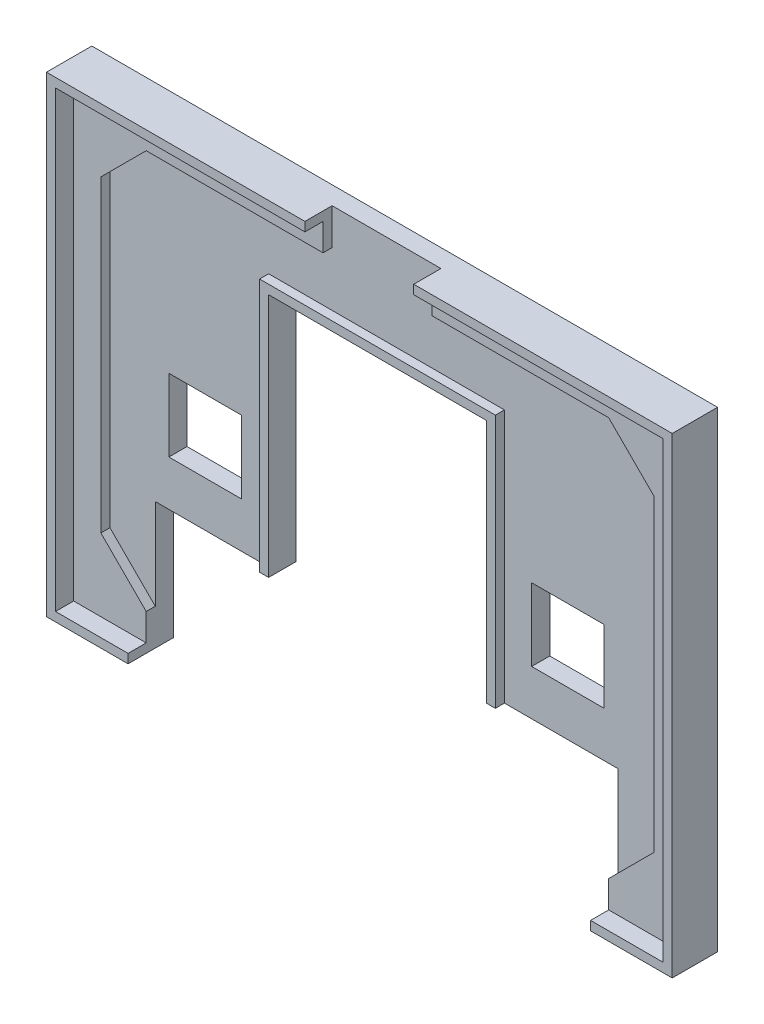
from build123d import *

# Parameters (mm, degrees)
SKICA1_W                    = 67
SKICA1_H                    = 50
P_IDAT_VYSUNUT_M1_DEPTH     = 3
ODEBRAT_VYSUNUT_M1_DEPTH    = 1
SKICA3_W                    = 8
SKICA3_H                    = 8
ODEBRAT_VYSUNUT_M2_DEPTH    = 4
VYSUNOUT_TENKOST_NN_1_DEPTH = 1
VYSUNOUT_TENKOST_NN_2_DEPTH = 5
SKICA6_W                    = 12
SKICA6_H                    = 4
ODEBRAT_VYSUNUT_M3_DEPTH    = 4
ODEBRAT_VYSUNUT_M4_DEPTH    = 1
ODEBRAT_VYSUNUT_M5_DEPTH    = 1


with BuildPart() as part:
    # Skica1 → Přidat vysunutím1 (new body)
    with BuildSketch(Plane.XY):
        Rectangle(SKICA1_W, SKICA1_H)
    extrude(amount=P_IDAT_VYSUNUT_M1_DEPTH)

    # Skica2 → Odebrat vysunutím1 (cut)
    with BuildSketch(Plane.XY.offset(3)):
        Polygon((-25.5, -22), (-30.5, -17), (-30.5, 17), (-25.5, 22), (25.5, 22), (30.5, 17), (30.5, -17), (25.5, -22), align=None)
    extrude(amount=-ODEBRAT_VYSUNUT_M1_DEPTH, mode=Mode.SUBTRACT)

    # Skica3 → Odebrat vysunutím2 (cut, through all)
    with BuildSketch(Plane(origin=(0, 0, 0), x_dir=(-1, 0, 0), z_dir=(0, 0, -1))):
        with Locations((20, -3)):
            Rectangle(SKICA3_W, SKICA3_H)
        with Locations((-20, -3)):
            Rectangle(SKICA3_W, SKICA3_H)
        Polygon((25.5, -25), (-25.5, -25), (-25.5, -12), (-12, -12), (-12, 15), (12, 15), (12, -12), (25.5, -12), align=None)
    extrude(amount=-ODEBRAT_VYSUNUT_M2_DEPTH, mode=Mode.SUBTRACT)

    # Skica4 → Vysunout tenkostěnný1 (add)
    with BuildSketch(Plane.XY.offset(2)):
        Polygon((-12, -12), (-12, 15), (12, 15), (12, -12), (13, -12), (13, 16), (-13, 16), (-13, -12), align=None)
    extrude(amount=VYSUNOUT_TENKOST_NN_1_DEPTH)

    # Skica5 → Vysunout tenkostěnný2 (add)
    with BuildSketch(Plane(origin=(0, 0, 0), x_dir=(-1, 0, 0), z_dir=(0, 0, -1))):
        Polygon((-25.5, -25), (-33.5, -25), (-33.5, 25), (33.5, 25), (33.5, -25), (25.5, -25), (25.5, -26), (34.5, -26), (34.5, 26), (-34.5, 26), (-34.5, -26), (-25.5, -26), align=None)
    extrude(amount=-VYSUNOUT_TENKOST_NN_2_DEPTH)

    # Skica6 → Odebrat vysunutím3 (cut, through all)
    with BuildSketch(Plane.XY.offset(2)):
        with Locations((0, 24)):
            Rectangle(SKICA6_W, SKICA6_H)
    extrude(amount=ODEBRAT_VYSUNUT_M3_DEPTH, mode=Mode.SUBTRACT)

    # Skica7 → Odebrat vysunutím4 (cut)
    with BuildSketch(Plane(origin=(0, 0, 0), x_dir=(-1, 0, 0), z_dir=(0, 0, -1))):
        Polygon((-29.257189592, 22.893008351), (-26.612015185, 22.893008351), (-26.612015185, 21.848860559), (-25.335834551, 21.848860559), (-25.335834551, 17.045780717), (-26.612015185, 17.045780717), (-26.612015185, 15.955226356), (-29.257189592, 15.955226356), (-29.257189592, 17.045780717), (-30.602980079, 17.045780717), (-30.602980079, 20.595883209), (-29.257189592, 20.595883209), align=None)
        Polygon((-19.952672602, 22.893008351), (-21.252056521, 22.893008351), (-21.252056521, 21.848860559), (-22.551440439, 21.848860559), (-22.551440439, 17.045780717), (-21.252056521, 17.045780717), (-21.252056521, 15.955226356), (-15.938504424, 15.955226356), (-15.938504424, 18.04352194), (-17.191481774, 18.04352194), (-17.191481774, 20.595883209), (-18.595280472, 20.595883209), (-18.595280472, 21.848860559), (-19.952672602, 21.848860559), align=None)
        Polygon((-30.602980079, 14.493419448), (-29.257189592, 14.493419448), (-29.257189592, 13.402865087), (-27.934602389, 13.402865087), (-27.934602389, 14.493419448), (-26.612015185, 14.493419448), (-26.612015185, 13.402865087), (-23.920434211, 13.402865087), (-23.920434211, 14.493419448), (-22.551440439, 14.493419448), (-22.551440439, 13.402865087), (-19.952672602, 13.402865087), (-19.952672602, 14.493419448), (-18.595280472, 14.493419448), (-18.595280472, 13.402865087), (-17.191481774, 13.402865087), (-17.191481774, 14.493419448), (-15.938504424, 14.493419448), (-15.938504424, 12.242700874), (-14.592713937, 12.242700874), (-14.592713937, 9.643933037), (-17.191481774, 9.643933037), (-17.191481774, 10.943316955), (-18.595280472, 10.943316955), (-18.595280472, 8.622988529), (-19.952672602, 8.622988529), (-19.952672602, 9.783152742), (-22.551440439, 9.783152742), (-22.551440439, 10.943316955), (-23.920434211, 10.943316955), (-23.920434211, 9.783152742), (-25.266224698, 9.783152742), (-25.266224698, 9.643933037), (-25.266224698, 8.622988529), (-26.612015185, 8.622988529), (-26.612015185, 10.943316955), (-27.934602389, 10.943316955), (-27.934602389, 9.643933037), (-29.257189592, 9.643933037), (-29.396409297, 9.643933037), (-29.396409297, 8.622988529), (-30.602980079, 8.622988529), (-30.602980079, 10.943316955), (-31.97197385, 10.943316955), (-31.97197385, 13.402865087), (-30.602980079, 13.402865087), align=None)
        Polygon((23.920434211, 9.783152742), (25.266224698, 9.783152742), (25.266224698, 9.643933037), (25.266224698, 8.622988529), (26.612015185, 8.622988529), (26.612015185, 10.943316955), (27.934602389, 10.943316955), (27.934602389, 9.643933037), (29.257189592, 9.643933037), (29.396409297, 9.643933037), (29.396409297, 8.622988529), (30.602980079, 8.622988529), (30.602980079, 10.943316955), (31.97197385, 10.943316955), (31.97197385, 13.402865087), (30.602980079, 13.402865087), (30.602980079, 14.493419448), (29.257189592, 14.493419448), (29.257189592, 13.402865087), (27.934602389, 13.402865087), (27.934602389, 14.493419448), (26.612015185, 14.493419448), (26.612015185, 13.402865087), (23.920434211, 13.402865087), (23.920434211, 14.493419448), (22.551440439, 14.493419448), (22.551440439, 13.402865087), (19.952672602, 13.402865087), (19.952672602, 14.493419448), (18.595280472, 14.493419448), (18.595280472, 13.402865087), (17.191481774, 13.402865087), (17.191481774, 14.493419448), (15.938504424, 14.493419448), (15.938504424, 12.242700874), (14.592713937, 12.242700874), (14.592713937, 9.643933037), (17.191481774, 9.643933037), (17.191481774, 10.943316955), (18.595280472, 10.943316955), (18.595280472, 8.622988529), (19.952672602, 8.622988529), (19.952672602, 9.783152742), (22.551440439, 9.783152742), (22.551440439, 10.943316955), (23.920434211, 10.943316955), align=None)
        Polygon((18.595280472, 21.848860559), (19.952672602, 21.848860559), (19.952672602, 22.893008351), (21.252056521, 22.893008351), (21.252056521, 21.848860559), (22.551440439, 21.848860559), (22.551440439, 17.045780717), (21.252056521, 17.045780717), (21.252056521, 15.955226356), (15.938504424, 15.955226356), (15.938504424, 18.04352194), (17.191481774, 18.04352194), (17.191481774, 20.595883209), (18.595280472, 20.595883209), align=None)
        Polygon((30.602980079, 20.595883209), (29.257189592, 20.595883209), (29.257189592, 22.893008351), (26.612015185, 22.893008351), (26.612015185, 21.848860559), (25.335834551, 21.848860559), (25.335834551, 17.045780717), (26.612015185, 17.045780717), (26.612015185, 15.955226356), (29.257189592, 15.955226356), (29.257189592, 17.045780717), (30.602980079, 17.045780717), align=None)
    extrude(amount=-ODEBRAT_VYSUNUT_M4_DEPTH, mode=Mode.SUBTRACT)

    # Skica8 → Odebrat vysunutím5 (cut)
    with BuildSketch(Plane(origin=(0, 0, 0), x_dir=(-1, 0, 0), z_dir=(0, 0, -1))):
        with BuildLine():
            add(Edge.make_bspline(
                [(-10.847232938, 22.82708346), (-10.846592487, 22.855861446), (-10.845391224, 22.909838983), (-10.841341175, 22.985738224), (-10.838152904, 23.05171888), (-10.833745096, 23.107762749), (-10.827344732, 23.153621635), (-10.822109294, 23.189512345), (-10.81537596, 23.215389421), (-10.803630622, 23.239888734), (-10.767463549, 23.257849053), (-10.709032498, 23.269282424), (-10.623172668, 23.278410789), (-10.530397944, 23.282452405), (-10.426453879, 23.285723657), (-10.308952592, 23.286198512), (-10.15550219, 23.287632538), (-9.966084133, 23.28872804), (-9.740302071, 23.289870296), (-9.478556149, 23.291413513), (-9.180442007, 23.290921624), (-8.969845503, 23.290996085), (-8.858353235, 23.291035506)],
                knots=[0, 0, 0, 0, 8.635e-05, 0.000161963, 0.000227997, 0.000284546, 0.000330495, 0.000366956, 0.000393139, 0.00041084, 0.000446424, 0.000506903, 0.000591368, 0.000704219, 0.000785775, 0.000903268, 0.001056724, 0.001246145, 0.001471531, 0.00173408, 0.002031393, 0.00236587, 0.00236587, 0.00236587, 0.00236587], degree=3))
            add(Edge.make_bspline(
                [(-8.858353235, 23.291035506), (-8.781626727, 23.291210694), (-8.632968006, 23.291550123), (-8.417183219, 23.289178891), (-8.215762162, 23.29081177), (-8.029162571, 23.286888665), (-7.856910535, 23.286760549), (-7.699070598, 23.283895751), (-7.555212749, 23.2814602), (-7.425711502, 23.279605178), (-7.310648325, 23.27548905), (-7.209893282, 23.272540012), (-7.123614489, 23.267398802), (-7.051632855, 23.262856217), (-6.994161048, 23.257955056), (-6.950642876, 23.253936774), (-6.921977591, 23.248374995), (-6.900217213, 23.241342845), (-6.887952998, 23.221635367), (-6.876426571, 23.195551877), (-6.865735488, 23.160439922), (-6.857475567, 23.116304859), (-6.852317493, 23.062918768), (-6.847100635, 23.000607594), (-6.845269934, 22.929392348), (-6.844635255, 22.879032172), (-6.844297841, 22.852259152)],
                knots=[0, 0, 0, 0, 0.000230178, 0.000445973, 0.000647378, 0.000834413, 0.001005852, 0.001164117, 0.001307998, 0.001437495, 0.00155264, 0.001653407, 0.001739857, 0.001811947, 0.001869691, 0.001913115, 0.001942505, 0.00195809, 0.001979435, 0.002008406, 0.002044808, 0.002088775, 0.002143055, 0.002205579, 0.002276351, 0.002356683, 0.002356683, 0.002356683, 0.002356683], degree=3))
            Line((-6.844297841, 22.852259152), (-6.844297841, 22.504594828))
            Line((-6.844297841, 22.504594828), (-6.579353649, 22.504594828))
            Line((-6.579353649, 22.504594828), (-6.463065927, 22.504594828))
            add(Edge.make_bspline(
                [(-6.463065927, 22.504594828), (-6.437010547, 22.503607805), (-6.389324864, 22.501801389), (-6.325227392, 22.485439746), (-6.27785123, 22.453695141), (-6.252452965, 22.415689464), (-6.24275747, 22.376518543), (-6.233680058, 22.336763538), (-6.228830898, 22.285657639), (-6.22425393, 22.224096449), (-6.218735037, 22.15221447), (-6.217521022, 22.06900721), (-6.214133866, 21.975127971), (-6.214640201, 21.908774163), (-6.21490553, 21.874003674)],
                knots=[0, 0, 0, 0, 7.8155e-05, 0.000143037, 0.000195581, 0.000245789, 0.00027576, 0.000316203, 0.0003681, 0.000429429, 0.000501519, 0.000584274, 0.000679013, 0.000783312, 0.000783312, 0.000783312, 0.000783312], degree=3))
            Line((-6.21490553, 21.874003674), (-6.21490553, 21.576690735))
            add(Edge.make_bspline(
                [(-6.21490553, 21.576690735), (-6.215384154, 21.513552917), (-6.21628385, 21.394869479), (-6.216371123, 21.228201084), (-6.220914344, 21.084758182), (-6.223494623, 20.964431418), (-6.229282274, 20.867187227), (-6.236822195, 20.793028127), (-6.242450039, 20.740866454), (-6.252178187, 20.715445619), (-6.255666175, 20.706331083)],
                knots=[0, 0, 0, 0, 0.000189421, 0.000356064, 0.00049997, 0.000619909, 0.0007172, 0.000791875, 0.000844104, 0.000873298, 0.000873298, 0.000873298, 0.000873298], degree=3))
            add(Edge.make_bspline(
                [(-6.255666175, 20.706331083), (-6.267247633, 20.697158974), (-6.296338203, 20.674120264), (-6.364539331, 20.658788881), (-6.45780779, 20.648940319), (-6.530103786, 20.648076172), (-6.570961751, 20.6475878)],
                knots=[0, 0, 0, 0, 4.3901e-05, 0.000110272, 0.000204402, 0.000326737, 0.000326737, 0.000326737, 0.000326737], degree=3))
            Line((-6.570961751, 20.6475878), (-6.844297841, 20.6475878))
            Line((-6.844297841, 20.6475878), (-6.844297841, 20.308315374))
            add(Edge.make_bspline(
                [(-6.844297841, 20.308315374), (-6.844583394, 20.280739391), (-6.845117366, 20.229173494), (-6.847573146, 20.156034169), (-6.850927091, 20.092447552), (-6.855585805, 20.037630215), (-6.861640301, 19.992450376), (-6.872578666, 19.956855503), (-6.880222845, 19.929396629), (-6.895570278, 19.905193331), (-6.937017585, 19.8946851), (-7.002702786, 19.887425563), (-7.105646428, 19.877018013), (-7.243827479, 19.871627784), (-7.418098076, 19.863359519), (-7.628736414, 19.859999034), (-7.874878817, 19.854169345), (-8.051128651, 19.853246797), (-8.14504195, 19.852755225)],
                knots=[0, 0, 0, 0, 8.2729e-05, 0.000154699, 0.000219537, 0.000273697, 0.000319818, 0.000355883, 0.000385076, 0.000405702, 0.000437982, 0.000505799, 0.000608151, 0.000746205, 0.000921384, 0.001131236, 0.001378244, 0.001659982, 0.001659982, 0.001659982, 0.001659982], degree=3))
            Line((-8.14504195, 19.852755225), (-9.363065927, 19.844363327))
            Line((-9.363065927, 19.844363327), (-9.363065927, 18.725843278))
            add(Edge.make_bspline(
                [(-9.363065927, 18.725843278), (-9.363753306, 18.638328597), (-9.365043366, 18.474082552), (-9.36850193, 18.244271491), (-9.373324999, 18.047322786), (-9.378562982, 17.883242817), (-9.38673514, 17.753109912), (-9.391323371, 17.654147743), (-9.402476596, 17.591981161), (-9.4079462, 17.548419559), (-9.438132786, 17.531455287), (-9.477383918, 17.521528755), (-9.536338952, 17.512378295), (-9.613430096, 17.504205722), (-9.710298026, 17.498901468), (-9.825767038, 17.493821278), (-9.96088565, 17.491997112), (-10.057196681, 17.491370756), (-10.10874596, 17.491035506)],
                knots=[0, 0, 0, 0, 0.000262557, 0.000492763, 0.000689432, 0.000853783, 0.000984654, 0.001082027, 0.001147471, 0.001180083, 0.00120336, 0.001244698, 0.001303037, 0.001381412, 0.001477506, 0.001593893, 0.001728185, 0.00188284, 0.00188284, 0.00188284, 0.00188284], degree=3))
            add(Edge.make_bspline(
                [(-10.10874596, 17.491035506), (-10.146309452, 17.491074723), (-10.21704071, 17.491148568), (-10.317349531, 17.490661728), (-10.405660691, 17.49220369), (-10.482784755, 17.493360177), (-10.547929066, 17.4944274), (-10.601461765, 17.495886588), (-10.643090205, 17.496367309), (-10.681481203, 17.49972708), (-10.718408989, 17.503798675), (-10.754805391, 17.514735479), (-10.78395607, 17.528671643), (-10.804644431, 17.545091928), (-10.815452949, 17.566574102), (-10.82207515, 17.592606318), (-10.82735812, 17.628430804), (-10.833739753, 17.674315094), (-10.838156868, 17.730349738), (-10.841329947, 17.796333786), (-10.845440237, 17.872230752), (-10.846808684, 17.94379757), (-10.848907269, 18.011722727), (-10.848008451, 18.077276488), (-10.849827691, 18.155990878), (-10.851236706, 18.248299513), (-10.850347853, 18.353807005), (-10.852543767, 18.472882844), (-10.851954188, 18.605160296), (-10.85169105, 18.751021677), (-10.853668117, 18.909662637), (-10.853183926, 19.081899728), (-10.852863782, 19.267322741), (-10.854887486, 19.466325742), (-10.854290448, 19.678523854), (-10.854466003, 19.904305333), (-10.854413631, 20.143274755), (-10.854432324, 20.391035506), (-10.854413631, 20.638796256), (-10.854466003, 20.877765678), (-10.854290448, 21.103547158), (-10.854887486, 21.31574527), (-10.852863782, 21.514748271), (-10.853183927, 21.700171284), (-10.853668114, 21.872408375), (-10.85169106, 22.031049335), (-10.851954154, 22.176910715), (-10.852543876, 22.30918817), (-10.85034751, 22.428263999), (-10.851237775, 22.533771521), (-10.849824444, 22.626080065), (-10.848017926, 22.704794726), (-10.848881028, 22.770347726), (-10.847743664, 22.809501647), (-10.847232938, 22.82708346)],
                knots=[0, 0, 0, 0, 0.000112691, 0.000212195, 0.000300918, 0.000377653, 0.0004436, 0.000496363, 0.000538339, 0.000568406, 0.000611979, 0.000649528, 0.000681696, 0.000708876, 0.000726576, 0.000752759, 0.000789221, 0.000835169, 0.000891719, 0.000957753, 0.001033366, 0.001119716, 0.001172478, 0.001237216, 0.001316349, 0.001408667, 0.001514165, 0.001632857, 0.001765928, 0.001910988, 0.002070439, 0.002241873, 0.002427694, 0.002626705, 0.002838901, 0.003064283, 0.003304051, 0.003555808, 0.003807565, 0.004047334, 0.004272716, 0.004484911, 0.004683923, 0.004869743, 0.005041178, 0.005200628, 0.005345688, 0.00547876, 0.005597451, 0.005702949, 0.005795268, 0.005874401, 0.005939138, 0.005991901, 0.005991901, 0.005991901, 0.005991901], degree=3))
        make_face()
        with BuildLine():
            add(Edge.make_bspline(
                [(-7.706265596, 20.937707684), (-7.706265596, 20.939306141), (-7.706265596, 20.946099582), (-7.706265596, 20.960885306), (-7.706265596, 20.986060998), (-7.706265596, 21.020827431), (-7.706265596, 21.065983832), (-7.706265596, 21.120730972), (-7.706265596, 21.185468467), (-7.706265596, 21.260196316), (-7.706265596, 21.344914519), (-7.706265596, 21.439623076), (-7.706265596, 21.544321988), (-7.706265596, 21.659011253), (-7.706265596, 21.783690873), (-7.706265596, 21.918360847), (-7.706265596, 22.063021175), (-7.706265596, 22.162924716), (-7.706265596, 22.214474944)],
                knots=[0, 0, 0, 0, 4.795e-06, 2.038e-05, 4.4357e-05, 8.0322e-05, 0.00012468, 0.000179826, 0.000244564, 0.000318892, 0.00040401, 0.000498718, 0.000603018, 0.000718107, 0.000842786, 0.000977057, 0.001122117, 0.001276767, 0.001276767, 0.001276767, 0.001276767], degree=3))
            Line((-7.706265596, 22.214474944), (-8.526273864, 22.222866841))
            add(Edge.make_bspline(
                [(-8.526273864, 22.222866841), (-8.528271935, 22.222866841), (-8.535864604, 22.222866841), (-8.553048013, 22.222866841), (-8.581420619, 22.222866841), (-8.621382035, 22.222866841), (-8.672532648, 22.222866841), (-8.735272072, 22.222866841), (-8.809200693, 22.222866841), (-8.862349377, 22.222866841), (-8.890721983, 22.222866841)],
                knots=[0, 0, 0, 0, 5.994e-06, 2.2778e-05, 5.155e-05, 9.1112e-05, 0.000142662, 0.000205002, 0.00027933, 0.000364448, 0.000364448, 0.000364448, 0.000364448], degree=3))
            add(Edge.make_bspline(
                [(-8.890721983, 22.222866841), (-8.927091971, 22.223134887), (-8.995046022, 22.223635706), (-9.089715447, 22.22042006), (-9.170131477, 22.218688039), (-9.235945598, 22.214956937), (-9.288398109, 22.211104396), (-9.325087202, 22.2040274), (-9.351410447, 22.201250394), (-9.360037131, 22.192404877), (-9.363065927, 22.189299251)],
                knots=[0, 0, 0, 0, 0.000109095, 0.000203834, 0.000284192, 0.000350226, 0.000401999, 0.000440827, 0.000464381, 0.000477125, 0.000477125, 0.000477125, 0.000477125], degree=3))
            add(Edge.make_bspline(
                [(-9.363065927, 22.189299251), (-9.363065927, 22.18530311), (-9.363065927, 22.168918929), (-9.363065927, 22.152534748), (-9.363065927, 22.140146709)],
                knots=[0, 0, 0, 0, 1.1988e-05, 4.9153e-05, 4.9153e-05, 4.9153e-05, 4.9153e-05], degree=3))
            add(Edge.make_bspline(
                [(-9.363065927, 22.140146709), (-9.363317147, 22.120560359), (-9.363886542, 22.076167452), (-9.368517891, 22.004319249), (-9.370410718, 21.924364368), (-9.371108825, 21.869208513), (-9.371457824, 21.841634927)],
                knots=[0, 0, 0, 0, 5.8756e-05, 0.000133171, 0.000215926, 0.000298654, 0.000298654, 0.000298654, 0.000298654], degree=3))
            add(Edge.make_bspline(
                [(-9.371457824, 21.841634927), (-9.371065998, 21.822853026), (-9.370082165, 21.775693635), (-9.368241315, 21.698946224), (-9.363927037, 21.618283988), (-9.363326939, 21.565905288), (-9.363065927, 21.543123145)],
                knots=[0, 0, 0, 0, 5.6358e-05, 0.00014151, 0.000230297, 0.000298642, 0.000298642, 0.000298642, 0.000298642], degree=3))
            Line((-9.363065927, 21.543123145), (-9.363065927, 20.937707684))
            Line((-9.363065927, 20.937707684), (-7.706265596, 20.937707684))
        make_face(mode=Mode.SUBTRACT)
        with BuildLine():
            add(Edge.make_bspline(
                [(-5.399692632, 22.872639474), (-5.398022344, 22.920179001), (-5.395100095, 23.003351663), (-5.387408162, 23.11137019), (-5.377478953, 23.184350498), (-5.362920546, 23.231575375), (-5.336890311, 23.254718932), (-5.307377892, 23.268729921), (-5.270650281, 23.277831769), (-5.233961396, 23.282428356), (-5.195543216, 23.285676177), (-5.153924058, 23.286195126), (-5.10038779, 23.287639616), (-5.035244783, 23.288712211), (-4.958120274, 23.289866863), (-4.86980926, 23.291409431), (-4.769500393, 23.290922399), (-4.698769143, 23.290996273), (-4.661205654, 23.291035506)],
                knots=[0, 0, 0, 0, 0.000142788, 0.000249815, 0.00032392, 0.000365328, 0.000393315, 0.000425484, 0.000462706, 0.000506278, 0.000536345, 0.000578322, 0.000631084, 0.000697032, 0.000773767, 0.000862489, 0.000961993, 0.001074684, 0.001074684, 0.001074684, 0.001074684], degree=3))
            add(Edge.make_bspline(
                [(-4.661205654, 23.291035506), (-4.609656889, 23.290699896), (-4.513346817, 23.290072867), (-4.378222008, 23.288253045), (-4.262771785, 23.283159684), (-4.165850428, 23.277892884), (-4.088903977, 23.269618875), (-4.029592852, 23.260718049), (-3.99112125, 23.250245036), (-3.964541976, 23.237146038), (-3.959864287, 23.211685163), (-3.955240661, 23.178715283), (-3.950959008, 23.127126816), (-3.945844164, 23.05857137), (-3.942924522, 22.972131391), (-3.939189785, 22.868260263), (-3.935679375, 22.747164538), (-3.932133519, 22.608499988), (-3.928229435, 22.452261257), (-3.926287389, 22.278013301), (-3.923883061, 22.086599425), (-3.921013643, 21.877607578), (-3.920784751, 21.651012426), (-3.917379808, 21.406861576), (-3.916821498, 21.145106589), (-3.915967052, 20.96488112), (-3.915525621, 20.871771347)],
                knots=[0, 0, 0, 0, 0.000154655, 0.000288947, 0.000405334, 0.000501428, 0.000579804, 0.000638142, 0.00067948, 0.000702757, 0.000719063, 0.000752972, 0.000804745, 0.000873247, 0.000959638, 0.001063999, 0.001185136, 0.00132305, 0.001480139, 0.001653988, 0.001845818, 0.00205443, 0.002281015, 0.00252559, 0.002786941, 0.003066273, 0.003066273, 0.003066273, 0.003066273], degree=3))
            Line((-3.915525621, 20.871771347), (-3.915525621, 18.568794911))
            add(Edge.make_bspline(
                [(-3.915525621, 18.568794911), (-3.91352755, 18.568794911), (-3.904736038, 18.568794911), (-3.885154944, 18.568794911), (-3.852786197, 18.568794911), (-3.807629796, 18.568794911), (-3.749685742, 18.568794911), (-3.678154806, 18.568794911), (-3.593836217, 18.568794911), (-3.496729975, 18.568794911), (-3.38683608, 18.568794911), (-3.264154531, 18.568794911), (-3.128285714, 18.568794911), (-2.979629245, 18.568794911), (-2.817785508, 18.568794911), (-2.642754503, 18.568794911), (-2.454935845, 18.568794911), (-2.325460856, 18.568794911), (-2.25872529, 18.568794911)],
                knots=[0, 0, 0, 0, 5.994e-06, 2.6375e-05, 5.8743e-05, 0.0001031, 0.000161844, 0.000232575, 0.000317693, 0.0004148, 0.000523894, 0.000647375, 0.000782844, 0.000931501, 0.001093344, 0.001268375, 0.001456594, 0.0016568, 0.0016568, 0.0016568, 0.0016568], degree=3))
            Line((-2.25872529, 18.568794911), (-2.25872529, 20.871771347))
            add(Edge.make_bspline(
                [(-2.25872529, 20.871771347), (-2.258283899, 20.964881121), (-2.257429533, 21.145106591), (-2.256870668, 21.406861566), (-2.253467631, 21.651012461), (-2.253232377, 21.877607464), (-2.250383976, 22.086599799), (-2.247910706, 22.278012076), (-2.246191489, 22.4522652), (-2.24157802, 22.608478792), (-2.240231053, 22.747185648), (-2.235920953, 22.868245528), (-2.233300981, 22.972189368), (-2.227491212, 23.058479421), (-2.224864399, 23.127163727), (-2.22016064, 23.178735857), (-2.215574567, 23.211641005), (-2.210875194, 23.237580145), (-2.183525226, 23.249506618), (-2.145305423, 23.261330552), (-2.085637689, 23.269293594), (-2.008437666, 23.277997997), (-1.911465839, 23.283122124), (-1.796033365, 23.288265661), (-1.660902702, 23.290068934), (-1.564593537, 23.290698525), (-1.513045257, 23.291035506)],
                knots=[0, 0, 0, 0, 0.000279333, 0.000540683, 0.000785259, 0.001011843, 0.001220456, 0.001412285, 0.001586134, 0.001743224, 0.001881111, 0.002002248, 0.002106609, 0.002193059, 0.002261488, 0.00231326, 0.002347169, 0.002363475, 0.002387749, 0.002427942, 0.002487463, 0.002565838, 0.002661933, 0.002778319, 0.002912611, 0.003067267, 0.003067267, 0.003067267, 0.003067267], degree=3))
            add(Edge.make_bspline(
                [(-1.513045257, 23.291035506), (-1.475481772, 23.290996085), (-1.40475053, 23.290921858), (-1.304441609, 23.291411222), (-1.216130766, 23.289861267), (-1.139405237, 23.288734875), (-1.074263785, 23.287598219), (-1.021124779, 23.286234866), (-0.979508914, 23.285646994), (-0.941091888, 23.282367719), (-0.904023898, 23.277882452), (-0.867102019, 23.269046343), (-0.838349224, 23.254352304), (-0.8125042, 23.231623553), (-0.797987331, 23.184322285), (-0.788016598, 23.111385526), (-0.780465622, 23.003335362), (-0.776492034, 22.905043801), (-0.774495185, 22.823487975), (-0.772897598, 22.766750963), (-0.773781459, 22.698800498), (-0.77198907, 22.619286376), (-0.770547331, 22.528576675), (-0.771470841, 22.426265626), (-0.769156685, 22.313184876), (-0.770307274, 22.188495732), (-0.768057428, 22.052635245), (-0.768624272, 21.90517322), (-0.768923017, 21.746923723), (-0.766903359, 21.577493006), (-0.767501638, 21.396464267), (-0.7673256, 21.203850858), (-0.76737598, 21.000047456), (-0.76736887, 20.860582138), (-0.767365224, 20.789051215)],
                knots=[0, 0, 0, 0, 0.000112691, 0.000212195, 0.000300918, 0.000377653, 0.000442401, 0.000496363, 0.000537141, 0.000567208, 0.000611968, 0.00064919, 0.000680291, 0.000708278, 0.000749686, 0.000823791, 0.000930818, 0.001073606, 0.001119178, 0.001175536, 0.00124387, 0.001323003, 0.001414123, 0.001516024, 0.001629921, 0.001753402, 0.001890075, 0.002037533, 0.00219578, 0.002364821, 0.002545846, 0.00273886, 0.002942663, 0.003157256, 0.003157256, 0.003157256, 0.003157256], degree=3))
            add(Edge.make_bspline(
                [(-0.767365224, 20.789051215), (-0.767202646, 20.693143445), (-0.766888326, 20.507720864), (-0.769079901, 20.238385018), (-0.768071044, 19.987023189), (-0.769910769, 19.753252045), (-0.770569144, 19.537852716), (-0.773129465, 19.340446386), (-0.776281763, 19.161034727), (-0.775893328, 18.999148879), (-0.780974356, 18.855335001), (-0.782301646, 18.729415654), (-0.786236747, 18.621525654), (-0.789937072, 18.531637528), (-0.792742103, 18.459179799), (-0.797999302, 18.404952161), (-0.801287617, 18.368178504), (-0.806394478, 18.350578375), (-0.808125869, 18.344611364)],
                knots=[0, 0, 0, 0, 0.000287722, 0.000556266, 0.000808023, 0.0010418, 0.001257595, 0.00145422, 0.001634062, 0.00179591, 0.001939816, 0.002065718, 0.002173673, 0.002263658, 0.002335679, 0.002391034, 0.002427317, 0.002445928, 0.002445928, 0.002445928, 0.002445928], degree=3))
            add(Edge.make_bspline(
                [(-0.808125869, 18.344611364), (-0.816834181, 18.330109113), (-0.833446476, 18.302444089), (-0.874583726, 18.284557065), (-0.917526949, 18.281543656), (-0.969196631, 18.28142915), (-1.039867018, 18.277652685), (-1.09344266, 18.278308217), (-1.123421445, 18.278675026)],
                knots=[0, 0, 0, 0, 4.9633e-05, 9.4681e-05, 0.000127249, 0.000178813, 0.000249586, 0.000339499, 0.000339499, 0.000339499, 0.000339499], degree=3))
            Line((-1.123421445, 18.278675026), (-1.396757535, 18.278675026))
            Line((-1.396757535, 18.278675026), (-1.396757535, 17.938203757))
            add(Edge.make_bspline(
                [(-1.396757535, 17.938203757), (-1.397215975, 17.911431553), (-1.398078129, 17.861083065), (-1.398414495, 17.789894754), (-1.402337667, 17.727539725), (-1.406877945, 17.673961919), (-1.412494655, 17.629425023), (-1.419858211, 17.594297662), (-1.426902879, 17.567393089), (-1.435274454, 17.554061979), (-1.438717022, 17.548579946)],
                knots=[0, 0, 0, 0, 8.0331e-05, 0.000151073, 0.000213517, 0.000267677, 0.000312438, 0.00034794, 0.000375618, 0.000394949, 0.000394949, 0.000394949, 0.000394949], degree=3))
            add(Edge.make_bspline(
                [(-1.438717022, 17.548579946), (-1.445415277, 17.541042752), (-1.460668756, 17.523878813), (-1.493465729, 17.515886355), (-1.530524881, 17.512134677), (-1.5760926, 17.506594744), (-1.638548443, 17.50437585), (-1.717184643, 17.49855064), (-1.811938271, 17.495443207), (-1.922248605, 17.493472398), (-2.048113865, 17.490256091), (-2.19319098, 17.491298567), (-2.364222576, 17.49094247), (-2.569225795, 17.491068002), (-2.811391587, 17.491025285), (-2.985623425, 17.491031946), (-3.078733558, 17.491035506)],
                knots=[0, 0, 0, 0, 2.9682e-05, 6.7593e-05, 9.6589e-05, 0.000142397, 0.00020484, 0.000284109, 0.000378886, 0.000489205, 0.000615106, 0.00075657, 0.000924408, 0.001128211, 0.001371576, 0.001650906, 0.001650906, 0.001650906, 0.001650906], degree=3))
            add(Edge.make_bspline(
                [(-3.078733558, 17.491035506), (-3.172642801, 17.491075159), (-3.350071327, 17.491150079), (-3.601031184, 17.490655413), (-3.821617176, 17.492206114), (-4.011831752, 17.493340809), (-4.171683941, 17.49443482), (-4.301142349, 17.495889738), (-4.400701058, 17.496310217), (-4.488963273, 17.499750649), (-4.569070296, 17.503029865), (-4.642179048, 17.514683916), (-4.695994203, 17.524778419), (-4.719419602, 17.542015462), (-4.728340834, 17.548579946)],
                knots=[0, 0, 0, 0, 0.000281728, 0.000532286, 0.000752876, 0.000943496, 0.001102947, 0.001232427, 0.001331938, 0.001401513, 0.001497607, 0.001571528, 0.001625048, 0.001657967, 0.001657967, 0.001657967, 0.001657967], degree=3))
            add(Edge.make_bspline(
                [(-4.728340834, 17.548579946), (-4.736272263, 17.563914351), (-4.75716882, 17.604315169), (-4.767433475, 17.689136221), (-4.775701978, 17.806029987), (-4.776845622, 17.895768312), (-4.777493376, 17.946595655)],
                knots=[0, 0, 0, 0, 5.1494e-05, 0.00013567, 0.00025226, 0.000404556, 0.000404556, 0.000404556, 0.000404556], degree=3))
            Line((-4.777493376, 17.946595655), (-4.777493376, 18.278675026))
            Line((-4.777493376, 18.278675026), (-5.050829465, 18.278675026))
            add(Edge.make_bspline(
                [(-5.050829465, 18.278675026), (-5.08080825, 18.278308217), (-5.134383892, 18.277652685), (-5.205054279, 18.28142915), (-5.256723962, 18.281543656), (-5.299667185, 18.284557065), (-5.340804434, 18.302444089), (-5.357416729, 18.330109113), (-5.366125042, 18.344611364)],
                knots=[0, 0, 0, 0, 8.9913e-05, 0.000160686, 0.00021225, 0.000244818, 0.000289866, 0.000339499, 0.000339499, 0.000339499, 0.000339499], degree=3))
            add(Edge.make_bspline(
                [(-5.366125042, 18.344611364), (-5.367856435, 18.350578375), (-5.372963304, 18.368178504), (-5.376251499, 18.404952163), (-5.381509534, 18.459179785), (-5.384309884, 18.531637603), (-5.388034479, 18.621525267), (-5.391850659, 18.729417532), (-5.393736596, 18.855317912), (-5.396270682, 18.999176425), (-5.398626472, 19.161021435), (-5.400919037, 19.340449112), (-5.40374398, 19.537851879), (-5.404321261, 19.7532523), (-5.40618553, 19.987023113), (-5.40516934, 20.23838504), (-5.407363049, 20.507720857), (-5.407048423, 20.693143442), (-5.406885687, 20.789051215)],
                knots=[0, 0, 0, 0, 1.8611e-05, 5.4895e-05, 0.000110249, 0.00018227, 0.000272255, 0.000380211, 0.000506112, 0.000649993, 0.000811855, 0.000991697, 0.001188322, 0.001404117, 0.001637894, 0.001889651, 0.002158194, 0.002445917, 0.002445917, 0.002445917, 0.002445917], degree=3))
            add(Edge.make_bspline(
                [(-5.406885687, 20.789051215), (-5.406882027, 20.860582138), (-5.406874892, 21.000047456), (-5.406925454, 21.203850859), (-5.40674878, 21.396464264), (-5.40734922, 21.577493015), (-5.405322268, 21.746923692), (-5.405645635, 21.905173323), (-5.406129813, 22.052634898), (-5.404153659, 22.188496877), (-5.404415151, 22.313179072), (-5.405001713, 22.426275881), (-5.402803487, 22.52856638), (-5.403701984, 22.61928981), (-5.402276218, 22.69881013), (-5.400475298, 22.766733828), (-5.401344336, 22.823497952), (-5.400202982, 22.857455533), (-5.399692632, 22.872639474)],
                knots=[0, 0, 0, 0, 0.000214593, 0.000418396, 0.00061141, 0.000792435, 0.000961476, 0.001119723, 0.001267181, 0.001403854, 0.001527335, 0.001641225, 0.001743134, 0.001834246, 0.001913378, 0.001981723, 0.002038068, 0.00208364, 0.00208364, 0.00208364, 0.00208364], degree=3))
        make_face()
        with BuildLine():
            add(Edge.make_bspline(
                [(0.047847674, 22.82708346), (0.048530192, 22.8558588), (0.04981036, 22.909831375), (0.053347651, 22.98578829), (0.058130293, 23.051732251), (0.063526674, 23.107830764), (0.071411049, 23.153601474), (0.077100874, 23.189893022), (0.086817743, 23.215501454), (0.099607559, 23.238116579), (0.124784858, 23.254746593), (0.160187717, 23.269070503), (0.204991422, 23.277751066), (0.249557432, 23.282406769), (0.295965904, 23.28567739), (0.34596377, 23.286197753), (0.409893607, 23.287622764), (0.487822268, 23.288729151), (0.579733251, 23.289854279), (0.685627588, 23.291417422), (0.805516739, 23.290920888), (0.890234545, 23.290995885), (0.934991122, 23.291035506)],
                knots=[0, 0, 0, 0, 8.635e-05, 0.000161963, 0.000228073, 0.000284737, 0.000330857, 0.000367535, 0.000394475, 0.000412775, 0.000444425, 0.00048205, 0.000527433, 0.000580521, 0.000616566, 0.000666932, 0.000730482, 0.000808416, 0.000900734, 0.001006239, 0.001126124, 0.001260394, 0.001260394, 0.001260394, 0.001260394], degree=3))
            add(Edge.make_bspline(
                [(0.934991122, 23.291035506), (0.995333605, 23.290740588), (1.108830272, 23.290185885), (1.26828666, 23.287845289), (1.405364438, 23.284385231), (1.520127337, 23.279929264), (1.612561066, 23.273658691), (1.683005628, 23.263457105), (1.731402778, 23.255948206), (1.763290317, 23.244010208), (1.77867972, 23.2219678), (1.790145841, 23.195093857), (1.800651047, 23.159245711), (1.80894981, 23.113889173), (1.814106426, 23.059323571), (1.819327711, 22.995809314), (1.821174356, 22.922998856), (1.821799995, 22.871439656), (1.822134569, 22.843867254)],
                knots=[0, 0, 0, 0, 0.000181029, 0.000340493, 0.000478407, 0.000592398, 0.000684989, 0.000756368, 0.000805271, 0.000833155, 0.0008545, 0.000883472, 0.00092102, 0.000966164, 0.001021636, 0.001085355, 0.001157326, 0.001240055, 0.001240055, 0.001240055, 0.001240055], degree=3))
            Line((1.822134569, 22.843867254), (1.822134569, 22.504594828))
            Line((1.822134569, 22.504594828), (2.144623201, 22.504594828))
            Line((2.144623201, 22.504594828), (2.161406996, 22.504594828))
            add(Edge.make_bspline(
                [(2.161406996, 22.504594828), (2.208550612, 22.503974536), (2.291781334, 22.502879429), (2.400530352, 22.494390437), (2.476107825, 22.480529672), (2.522061156, 22.458962407), (2.539810079, 22.43110882), (2.548455833, 22.403394903), (2.558413361, 22.368006522), (2.565139291, 22.322955099), (2.56941451, 22.269281442), (2.573041986, 22.206519594), (2.575331459, 22.134967356), (2.575904337, 22.084202448), (2.5762065, 22.057426577)],
                knots=[0, 0, 0, 0, 0.000141509, 0.00024983, 0.00032603, 0.00037332, 0.000394932, 0.000422996, 0.000460218, 0.000505155, 0.000559316, 0.000621759, 0.00069373, 0.000774061, 0.000774061, 0.000774061, 0.000774061], degree=3))
            Line((2.5762065, 22.057426577), (2.5762065, 21.70856341))
            Line((2.5762065, 21.70856341), (3.072527294, 21.70856341))
            Line((3.072527294, 21.70856341), (3.072527294, 22.049034679))
            add(Edge.make_bspline(
                [(3.072527294, 22.049034679), (3.073164895, 22.099747926), (3.074291, 22.189315584), (3.082642802, 22.307061174), (3.097075726, 22.388980175), (3.1210486, 22.449829311), (3.178090747, 22.476457612), (3.252982379, 22.493901717), (3.360163486, 22.503027414), (3.441402013, 22.504028759), (3.487326798, 22.504594828)],
                knots=[0, 0, 0, 0, 0.000152295, 0.000268978, 0.000352209, 0.000404753, 0.000454718, 0.000531481, 0.00063753, 0.000775444, 0.000775444, 0.000775444, 0.000775444], degree=3))
            Line((3.487326798, 22.504594828), (3.504110593, 22.504594828))
            Line((3.504110593, 22.504594828), (3.826599224, 22.504594828))
            Line((3.826599224, 22.504594828), (3.826599224, 22.843867254))
            add(Edge.make_bspline(
                [(3.826599224, 22.843867254), (3.826874263, 22.870646532), (3.827395715, 22.921417898), (3.830025099, 22.992927452), (3.832583672, 23.05546413), (3.839904862, 23.108335869), (3.843702435, 23.15309372), (3.85483669, 23.187582804), (3.862319033, 23.215329315), (3.872596807, 23.228086818), (3.876950609, 23.233491066)],
                knots=[0, 0, 0, 0, 8.0331e-05, 0.000152302, 0.000214745, 0.000267834, 0.000312594, 0.000348659, 0.000376723, 0.000397349, 0.000397349, 0.000397349, 0.000397349], degree=3))
            add(Edge.make_bspline(
                [(3.876950609, 23.233491066), (3.884786816, 23.238262122), (3.906445265, 23.251448819), (3.954704493, 23.260218576), (4.023669927, 23.269836918), (4.115829682, 23.277874926), (4.230956753, 23.283134696), (4.368839869, 23.288277632), (4.529515514, 23.29005922), (4.644209735, 23.290696034), (4.705350775, 23.291035506)],
                knots=[0, 0, 0, 0, 2.7364e-05, 7.5631e-05, 0.000144635, 0.000237327, 0.000352572, 0.000490522, 0.000651185, 0.000834612, 0.000834612, 0.000834612, 0.000834612], degree=3))
            add(Edge.make_bspline(
                [(4.705350775, 23.291035506), (4.75050697, 23.290996003), (4.836423625, 23.290920841), (4.957911178, 23.291421187), (5.065404043, 23.289853531), (5.158513663, 23.288727636), (5.237641691, 23.287621615), (5.30236937, 23.286200588), (5.352770801, 23.285695633), (5.399563533, 23.28231898), (5.444193332, 23.278032987), (5.488896067, 23.268860607), (5.523951111, 23.254759888), (5.549126606, 23.238114888), (5.56191447, 23.215501846), (5.571644325, 23.18989388), (5.577256685, 23.153595234), (5.585545638, 23.107901285), (5.588881048, 23.051643928), (5.59436286, 22.985804922), (5.597657988, 22.909825783), (5.599462997, 22.838277247), (5.600955859, 22.770340397), (5.60254548, 22.704809117), (5.601664091, 22.626071829), (5.603449095, 22.533768505), (5.604899149, 22.42827287), (5.603973471, 22.309179357), (5.606292112, 22.176915716), (5.605133606, 22.03104835), (5.60738471, 21.872408671), (5.606818006, 21.700171195), (5.606522662, 21.514748297), (5.608538985, 21.315745262), (5.607944124, 21.10354716), (5.608119039, 20.877765677), (5.608066858, 20.638796257), (5.608085483, 20.391035506), (5.608066858, 20.143274755), (5.608119039, 19.904305334), (5.607944124, 19.678523852), (5.608538985, 19.466325749), (5.606522662, 19.267322714), (5.606818006, 19.081899817), (5.60738471, 18.90966234), (5.605133606, 18.751022661), (5.606292112, 18.605155296), (5.603973472, 18.472891654), (5.604899149, 18.353798142), (5.603449095, 18.248302506), (5.60166409, 18.155999184), (5.602545481, 18.077261893), (5.600955855, 18.01173062), (5.599463012, 17.943793745), (5.597657896, 17.872245344), (5.594363137, 17.796265743), (5.588880211, 17.730428131), (5.585548072, 17.674166678), (5.577250026, 17.628484117), (5.571661582, 17.592155518), (5.561874507, 17.566619218), (5.54937024, 17.544008609), (5.523488209, 17.528699204), (5.488818801, 17.514601379), (5.444377827, 17.503559246), (5.399546615, 17.499840612), (5.352776213, 17.496347039), (5.302367211, 17.495881729), (5.237642483, 17.494445248), (5.158513387, 17.493344818), (5.065404134, 17.492217004), (4.957911148, 17.49064998), (4.836423633, 17.491150124), (4.750506973, 17.491074993), (4.705350775, 17.491035506)],
                knots=[0, 0, 0, 0, 0.000135469, 0.000257751, 0.000364455, 0.000457972, 0.000537105, 0.000601854, 0.000652219, 0.000688264, 0.000742544, 0.000786755, 0.000824381, 0.000856031, 0.000874331, 0.000901271, 0.000937949, 0.000984069, 0.001040618, 0.001106729, 0.001182342, 0.001268691, 0.001321454, 0.001386203, 0.001465326, 0.001557645, 0.00166315, 0.001781835, 0.001914912, 0.002059972, 0.002219423, 0.002390857, 0.002576678, 0.002775689, 0.002987884, 0.003213267, 0.003453035, 0.003704792, 0.003956549, 0.004196318, 0.0044217, 0.004633895, 0.004832907, 0.005018727, 0.005190162, 0.005349612, 0.005494672, 0.005627749, 0.005746435, 0.00585194, 0.005944258, 0.006023382, 0.00608813, 0.006140893, 0.006227243, 0.006302856, 0.006368966, 0.006425515, 0.006471636, 0.006508313, 0.006535254, 0.006553554, 0.006584492, 0.006622117, 0.006666604, 0.006720884, 0.006756929, 0.006807295, 0.006872043, 0.006951176, 0.007044693, 0.007151397, 0.007273679, 0.007409148, 0.007409148, 0.007409148, 0.007409148], degree=3))
            add(Edge.make_bspline(
                [(4.705350775, 17.491035506), (4.644209735, 17.491374978), (4.529515514, 17.492011792), (4.368839869, 17.49379338), (4.230956753, 17.498936315), (4.115829682, 17.504196086), (4.023669927, 17.512234094), (3.954704493, 17.521852436), (3.906445265, 17.530622192), (3.884786816, 17.543808889), (3.876950609, 17.548579946)],
                knots=[0, 0, 0, 0, 0.000183427, 0.00034409, 0.00048204, 0.000597285, 0.000689976, 0.00075898, 0.000807247, 0.000834612, 0.000834612, 0.000834612, 0.000834612], degree=3))
            add(Edge.make_bspline(
                [(3.876950609, 17.548579946), (3.875221274, 17.552535976), (3.870217048, 17.563983651), (3.866888376, 17.588138243), (3.861865177, 17.622788383), (3.856932887, 17.669178536), (3.854068942, 17.72680074), (3.850192329, 17.796322213), (3.84677533, 17.877054863), (3.843247137, 17.969367842), (3.839282472, 18.072848674), (3.837364616, 18.187963302), (3.83495958, 18.314638765), (3.83208484, 18.452895628), (3.831866018, 18.602372516), (3.828445647, 18.763396502), (3.827900157, 18.935642039), (3.827041541, 19.054326626), (3.826599224, 19.115467089)],
                knots=[0, 0, 0, 0, 1.2912e-05, 3.7364e-05, 7.2459e-05, 0.000118267, 0.00017712, 0.000245549, 0.000327149, 0.00041953, 0.000522693, 0.000637807, 0.000764907, 0.000902795, 0.001052655, 0.001213318, 0.001385955, 0.001569382, 0.001569382, 0.001569382, 0.001569382], degree=3))
            Line((3.826599224, 19.115467089), (3.818207327, 20.632002848))
            add(Edge.make_bspline(
                [(3.818207327, 20.632002848), (3.784656407, 20.635049954), (3.704871586, 20.642296041), (3.600009263, 20.646235677), (3.507730827, 20.65135752), (3.442955708, 20.653140377), (3.387851505, 20.656504312), (3.353859261, 20.656141717), (3.338670328, 20.655979698)],
                knots=[0, 0, 0, 0, 0.000101052, 0.000240303, 0.000314719, 0.000378303, 0.000434699, 0.000480255, 0.000480255, 0.000480255, 0.000480255], degree=3))
            Line((3.338670328, 20.655979698), (3.338670328, 20.308315374))
            Line((3.338670328, 20.308315374), (3.338670328, 20.242379036))
            add(Edge.make_bspline(
                [(3.338670328, 20.242379036), (3.338075564, 20.20043967), (3.337013719, 20.125564412), (3.328016877, 20.026798627), (3.310568076, 19.957130678), (3.283312158, 19.905235674), (3.225596804, 19.883825523), (3.148245787, 19.870203685), (3.037745198, 19.863359461), (2.954201363, 19.861944875), (2.907087029, 19.861147122)],
                knots=[0, 0, 0, 0, 0.00012593, 0.000224825, 0.0002958, 0.000342693, 0.000392021, 0.000471489, 0.000580906, 0.000722415, 0.000722415, 0.000722415, 0.000722415], degree=3))
            Line((2.907087029, 19.861147122), (2.832758794, 19.861147122))
            Line((2.832758794, 19.861147122), (2.750038662, 19.861147122))
            add(Edge.make_bspline(
                [(2.750038662, 19.861147122), (2.702894544, 19.861790127), (2.618867209, 19.862936187), (2.507762812, 19.871445883), (2.428114539, 19.885798469), (2.369607176, 19.91014517), (2.338872199, 19.96185357), (2.32281547, 20.031947833), (2.310897216, 20.12813241), (2.310364157, 20.201176162), (2.310063466, 20.242379036)],
                knots=[0, 0, 0, 0, 0.000141509, 0.000252219, 0.000333103, 0.000385647, 0.000434858, 0.000505833, 0.000601298, 0.000724831, 0.000724831, 0.000724831, 0.000724831], degree=3))
            Line((2.310063466, 20.242379036), (2.310063466, 20.308315374))
            Line((2.310063466, 20.308315374), (2.310063466, 20.655979698))
            add(Edge.make_bspline(
                [(2.310063466, 20.655979698), (2.294874294, 20.656148163), (2.261280859, 20.656520753), (2.206180439, 20.653071269), (2.141400941, 20.651401469), (2.049122394, 20.646262201), (1.944269533, 20.642190858), (1.864477487, 20.635043854), (1.830526467, 20.632002848)],
                knots=[0, 0, 0, 0, 4.5556e-05, 0.000100755, 0.000165537, 0.000239952, 0.000378006, 0.000480253, 0.000480253, 0.000480253, 0.000480253], degree=3))
            Line((1.830526467, 20.632002848), (1.822134569, 19.115467089))
            add(Edge.make_bspline(
                [(1.822134569, 19.115467089), (1.821692253, 19.054326626), (1.820833637, 18.935642039), (1.820288147, 18.763396502), (1.816867776, 18.602372516), (1.816648954, 18.452895628), (1.813774214, 18.314638765), (1.811369177, 18.187963302), (1.809451322, 18.072848674), (1.805486657, 17.969367842), (1.801958464, 17.877054863), (1.798541464, 17.796322213), (1.794664852, 17.72680074), (1.791800907, 17.669178536), (1.786868616, 17.622788383), (1.781845418, 17.588138243), (1.778516745, 17.563983651), (1.77351252, 17.552535976), (1.771783185, 17.548579946)],
                knots=[0, 0, 0, 0, 0.000183427, 0.000356064, 0.000516727, 0.000666587, 0.000804475, 0.000931575, 0.001046689, 0.001149852, 0.001242233, 0.001323833, 0.001392262, 0.001451115, 0.001496923, 0.001532019, 0.00155647, 0.001569382, 0.001569382, 0.001569382, 0.001569382], degree=3))
            add(Edge.make_bspline(
                [(1.771783185, 17.548579946), (1.763946978, 17.543808889), (1.742288529, 17.530622192), (1.694029301, 17.521852436), (1.625063867, 17.512234094), (1.532904112, 17.504196086), (1.41777704, 17.498936315), (1.279893925, 17.49379338), (1.11921828, 17.492011792), (1.004524059, 17.491374978), (0.943383019, 17.491035506)],
                knots=[0, 0, 0, 0, 2.7364e-05, 7.5631e-05, 0.000144635, 0.000237327, 0.000352572, 0.000490522, 0.000651185, 0.000834612, 0.000834612, 0.000834612, 0.000834612], degree=3))
            add(Edge.make_bspline(
                [(0.943383019, 17.491035506), (0.898226823, 17.491075005), (0.812310166, 17.491150157), (0.690822627, 17.49064987), (0.583329716, 17.492217342), (0.490220237, 17.493343794), (0.411091799, 17.494448195), (0.346365253, 17.495873698), (0.295960916, 17.496367172), (0.249572913, 17.499748806), (0.204817732, 17.503864544), (0.160256425, 17.51438218), (0.125248454, 17.52871406), (0.09936381, 17.544006682), (0.086857735, 17.566619692), (0.077083617, 17.592156341), (0.071417643, 17.628477891), (0.063524593, 17.674237191), (0.058129334, 17.730339795), (0.053355759, 17.796282454), (0.049772138, 17.872239393), (0.048250544, 17.943796168), (0.046179003, 18.011723098), (0.047070117, 18.077276354), (0.045253621, 18.155990923), (0.043843676, 18.248299498), (0.044732833, 18.35380701), (0.042536821, 18.472882842), (0.043126431, 18.605160297), (0.04338956, 18.751021677), (0.041412496, 18.909662637), (0.041896685, 19.081899728), (0.042216829, 19.267322741), (0.040193126, 19.466325742), (0.040790164, 19.678523854), (0.040614609, 19.904305333), (0.040666981, 20.143274755), (0.040648288, 20.391035506), (0.040666981, 20.638796256), (0.040614609, 20.877765678), (0.040790164, 21.103547158), (0.040193125, 21.31574527), (0.04221683, 21.514748271), (0.041896684, 21.700171284), (0.041412498, 21.872408375), (0.043389552, 22.031049335), (0.043126457, 22.176910715), (0.042536736, 22.30918817), (0.044733102, 22.428263999), (0.043842837, 22.533771521), (0.045256167, 22.626080065), (0.047062686, 22.704794726), (0.046199584, 22.770347726), (0.047336948, 22.809501647), (0.047847674, 22.82708346)],
                knots=[0, 0, 0, 0, 0.000135469, 0.000257751, 0.000364455, 0.000457972, 0.000537105, 0.000601854, 0.000652219, 0.000688264, 0.000741353, 0.000787003, 0.000824629, 0.000855567, 0.000873867, 0.000900807, 0.000937485, 0.000983605, 0.001040269, 0.001106379, 0.001181992, 0.001268342, 0.001321105, 0.001385842, 0.001464975, 0.001557294, 0.001662792, 0.001781483, 0.001914555, 0.002059615, 0.002219065, 0.0023905, 0.00257632, 0.002775332, 0.002987527, 0.003212909, 0.003452678, 0.003704435, 0.003956192, 0.00419596, 0.004421342, 0.004633538, 0.004832549, 0.00501837, 0.005189804, 0.005349255, 0.005494315, 0.005627386, 0.005746078, 0.005851576, 0.005943894, 0.006023027, 0.006087765, 0.006140527, 0.006140527, 0.006140527, 0.006140527], degree=3))
        make_face()
        with BuildLine():
            add(Edge.make_bspline(
                [(6.416099018, 22.82708346), (6.416739468, 22.855861446), (6.417940732, 22.909838983), (6.42199078, 22.985738224), (6.425179051, 23.05171888), (6.429586859, 23.107762749), (6.435987223, 23.153621635), (6.441222661, 23.189512345), (6.447955995, 23.215389421), (6.459701333, 23.239888734), (6.495868406, 23.257849053), (6.554299457, 23.269282424), (6.640159287, 23.278410789), (6.732934012, 23.282452405), (6.836878076, 23.285723657), (6.954379363, 23.286198512), (7.107829765, 23.287632538), (7.297247822, 23.28872804), (7.523029884, 23.289870296), (7.784775807, 23.291413513), (8.082889948, 23.290921624), (8.293486453, 23.290996085), (8.40497872, 23.291035506)],
                knots=[0, 0, 0, 0, 8.635e-05, 0.000161963, 0.000227997, 0.000284546, 0.000330495, 0.000366956, 0.000393139, 0.00041084, 0.000446424, 0.000506903, 0.000591368, 0.000704219, 0.000785775, 0.000903268, 0.001056724, 0.001246145, 0.001471531, 0.00173408, 0.002031393, 0.00236587, 0.00236587, 0.00236587, 0.00236587], degree=3))
            add(Edge.make_bspline(
                [(8.40497872, 23.291035506), (8.481705229, 23.291210694), (8.63036395, 23.291550123), (8.846148736, 23.289178891), (9.047569794, 23.29081177), (9.234169384, 23.286888665), (9.40642142, 23.286760549), (9.564261358, 23.283895751), (9.708119206, 23.2814602), (9.837620453, 23.279605178), (9.952683631, 23.27548905), (10.053438674, 23.272540012), (10.139717466, 23.267398802), (10.211699101, 23.262856217), (10.269170908, 23.257955056), (10.312689079, 23.253936774), (10.341354364, 23.248374995), (10.363114743, 23.241342845), (10.375378957, 23.221635367), (10.386905384, 23.195551877), (10.397596467, 23.160439922), (10.405856389, 23.116304859), (10.411014462, 23.062918768), (10.41623132, 23.000607594), (10.418062021, 22.929392348), (10.4186967, 22.879032172), (10.419034115, 22.852259152)],
                knots=[0, 0, 0, 0, 0.000230178, 0.000445973, 0.000647378, 0.000834413, 0.001005852, 0.001164117, 0.001307998, 0.001437495, 0.00155264, 0.001653407, 0.001739857, 0.001811947, 0.001869691, 0.001913115, 0.001942505, 0.00195809, 0.001979435, 0.002008406, 0.002044808, 0.002088775, 0.002143055, 0.002205579, 0.002276351, 0.002356683, 0.002356683, 0.002356683, 0.002356683], degree=3))
            Line((10.419034115, 22.852259152), (10.419034115, 22.504594828))
            Line((10.419034115, 22.504594828), (10.683978307, 22.504594828))
            Line((10.683978307, 22.504594828), (10.800266029, 22.504594828))
            add(Edge.make_bspline(
                [(10.800266029, 22.504594828), (10.826321408, 22.503607805), (10.874007092, 22.501801389), (10.938104563, 22.485439746), (10.985480725, 22.453695141), (11.01087899, 22.415689464), (11.020574486, 22.376518543), (11.029651898, 22.336763538), (11.034501057, 22.285657639), (11.039078026, 22.224096449), (11.044596918, 22.15221447), (11.045810933, 22.06900721), (11.04919809, 21.975127971), (11.048691754, 21.908774163), (11.048426426, 21.874003674)],
                knots=[0, 0, 0, 0, 7.8155e-05, 0.000143037, 0.000195581, 0.000245789, 0.00027576, 0.000316203, 0.0003681, 0.000429429, 0.000501519, 0.000584274, 0.000679013, 0.000783312, 0.000783312, 0.000783312, 0.000783312], degree=3))
            Line((11.048426426, 21.874003674), (11.048426426, 21.576690735))
            add(Edge.make_bspline(
                [(11.048426426, 21.576690735), (11.047947801, 21.513552917), (11.047048106, 21.394869479), (11.046960832, 21.228201084), (11.042417611, 21.084758182), (11.039837332, 20.964431418), (11.034049682, 20.867187227), (11.02650976, 20.793028127), (11.020881917, 20.740866454), (11.011153769, 20.715445619), (11.007665781, 20.706331083)],
                knots=[0, 0, 0, 0, 0.000189421, 0.000356064, 0.00049997, 0.000619909, 0.0007172, 0.000791875, 0.000844104, 0.000873298, 0.000873298, 0.000873298, 0.000873298], degree=3))
            add(Edge.make_bspline(
                [(11.007665781, 20.706331083), (10.996084322, 20.697158974), (10.966993752, 20.674120264), (10.898792624, 20.658788881), (10.805524166, 20.648940319), (10.733228169, 20.648076172), (10.692370204, 20.6475878)],
                knots=[0, 0, 0, 0, 4.3901e-05, 0.000110272, 0.000204402, 0.000326737, 0.000326737, 0.000326737, 0.000326737], degree=3))
            Line((10.692370204, 20.6475878), (10.419034115, 20.6475878))
            Line((10.419034115, 20.6475878), (10.419034115, 20.308315374))
            add(Edge.make_bspline(
                [(10.419034115, 20.308315374), (10.418748562, 20.280739391), (10.41821459, 20.229173494), (10.415758809, 20.156034169), (10.412404864, 20.092447552), (10.407746151, 20.037630215), (10.401691654, 19.992450376), (10.390753289, 19.956855503), (10.383109111, 19.929396629), (10.367761678, 19.905193331), (10.32631437, 19.8946851), (10.260629169, 19.887425563), (10.157685528, 19.877018013), (10.019504476, 19.871627784), (9.84523388, 19.863359519), (9.634595542, 19.859999034), (9.388453138, 19.854169345), (9.212203305, 19.853246797), (9.118290006, 19.852755225)],
                knots=[0, 0, 0, 0, 8.2729e-05, 0.000154699, 0.000219537, 0.000273697, 0.000319818, 0.000355883, 0.000385076, 0.000405702, 0.000437982, 0.000505799, 0.000608151, 0.000746205, 0.000921384, 0.001131236, 0.001378244, 0.001659982, 0.001659982, 0.001659982, 0.001659982], degree=3))
            Line((9.118290006, 19.852755225), (7.900266029, 19.844363327))
            Line((7.900266029, 19.844363327), (7.900266029, 18.725843278))
            add(Edge.make_bspline(
                [(7.900266029, 18.725843278), (7.89957865, 18.638328597), (7.898288589, 18.474082552), (7.894830026, 18.244271491), (7.890006957, 18.047322786), (7.884768973, 17.883242817), (7.876596815, 17.753109912), (7.872008584, 17.654147743), (7.860855359, 17.591981161), (7.855385755, 17.548419559), (7.825199169, 17.531455287), (7.785948038, 17.521528755), (7.726993003, 17.512378295), (7.649901859, 17.504205722), (7.553033929, 17.498901468), (7.437564917, 17.493821278), (7.302446305, 17.491997112), (7.206135274, 17.491370756), (7.154585996, 17.491035506)],
                knots=[0, 0, 0, 0, 0.000262557, 0.000492763, 0.000689432, 0.000853783, 0.000984654, 0.001082027, 0.001147471, 0.001180083, 0.00120336, 0.001244698, 0.001303037, 0.001381412, 0.001477506, 0.001593893, 0.001728185, 0.00188284, 0.00188284, 0.00188284, 0.00188284], degree=3))
            add(Edge.make_bspline(
                [(7.154585996, 17.491035506), (7.117022503, 17.491074723), (7.046291245, 17.491148568), (6.945982425, 17.490661728), (6.857671264, 17.49220369), (6.780547201, 17.493360177), (6.71540289, 17.4944274), (6.66187019, 17.495886588), (6.620241751, 17.496367309), (6.581850752, 17.49972708), (6.544922966, 17.503798675), (6.508526564, 17.514735479), (6.479375886, 17.528671643), (6.458687524, 17.545091928), (6.447879006, 17.566574102), (6.441256805, 17.592606318), (6.435973835, 17.628430804), (6.429592202, 17.674315094), (6.425175087, 17.730349738), (6.422002008, 17.796333786), (6.417891718, 17.872230752), (6.416523271, 17.94379757), (6.414424686, 18.011722727), (6.415323504, 18.077276488), (6.413504264, 18.155990878), (6.41209525, 18.248299513), (6.412984102, 18.353807005), (6.410788189, 18.472882844), (6.411377767, 18.605160296), (6.411640906, 18.751021677), (6.409663839, 18.909662637), (6.410148029, 19.081899728), (6.410468173, 19.267322741), (6.408444469, 19.466325742), (6.409041507, 19.678523854), (6.408865952, 19.904305333), (6.408918324, 20.143274755), (6.408899631, 20.391035506), (6.408918324, 20.638796256), (6.408865952, 20.877765678), (6.409041507, 21.103547158), (6.408444469, 21.31574527), (6.410468173, 21.514748271), (6.410148028, 21.700171284), (6.409663842, 21.872408375), (6.411640895, 22.031049335), (6.411377801, 22.176910715), (6.410788079, 22.30918817), (6.412984445, 22.428263999), (6.412094181, 22.533771521), (6.413507511, 22.626080065), (6.41531403, 22.704794726), (6.414450928, 22.770347726), (6.415588292, 22.809501647), (6.416099018, 22.82708346)],
                knots=[0, 0, 0, 0, 0.000112691, 0.000212195, 0.000300918, 0.000377653, 0.0004436, 0.000496363, 0.000538339, 0.000568406, 0.000611979, 0.000649528, 0.000681696, 0.000708876, 0.000726576, 0.000752759, 0.000789221, 0.000835169, 0.000891719, 0.000957753, 0.001033366, 0.001119716, 0.001172478, 0.001237216, 0.001316349, 0.001408667, 0.001514165, 0.001632857, 0.001765928, 0.001910988, 0.002070439, 0.002241873, 0.002427694, 0.002626705, 0.002838901, 0.003064283, 0.003304051, 0.003555808, 0.003807565, 0.004047334, 0.004272716, 0.004484911, 0.004683923, 0.004869743, 0.005041178, 0.005200628, 0.005345688, 0.00547876, 0.005597451, 0.005702949, 0.005795268, 0.005874401, 0.005939138, 0.005991901, 0.005991901, 0.005991901, 0.005991901], degree=3))
        make_face()
        with BuildLine():
            add(Edge.make_bspline(
                [(9.557066359, 20.937707684), (9.557066359, 20.939306141), (9.557066359, 20.946099582), (9.557066359, 20.960885306), (9.557066359, 20.986060998), (9.557066359, 21.020827431), (9.557066359, 21.065983832), (9.557066359, 21.120730972), (9.557066359, 21.185468467), (9.557066359, 21.260196316), (9.557066359, 21.344914519), (9.557066359, 21.439623076), (9.557066359, 21.544321988), (9.557066359, 21.659011253), (9.557066359, 21.783690873), (9.557066359, 21.918360847), (9.557066359, 22.063021175), (9.557066359, 22.162924716), (9.557066359, 22.214474944)],
                knots=[0, 0, 0, 0, 4.795e-06, 2.038e-05, 4.4357e-05, 8.0322e-05, 0.00012468, 0.000179826, 0.000244564, 0.000318892, 0.00040401, 0.000498718, 0.000603018, 0.000718107, 0.000842786, 0.000977057, 0.001122117, 0.001276767, 0.001276767, 0.001276767, 0.001276767], degree=3))
            Line((9.557066359, 22.214474944), (8.737058092, 22.222866841))
            add(Edge.make_bspline(
                [(8.737058092, 22.222866841), (8.735060021, 22.222866841), (8.727467352, 22.222866841), (8.710283942, 22.222866841), (8.681911337, 22.222866841), (8.64194992, 22.222866841), (8.590799307, 22.222866841), (8.528059883, 22.222866841), (8.454131262, 22.222866841), (8.400982578, 22.222866841), (8.372609973, 22.222866841)],
                knots=[0, 0, 0, 0, 5.994e-06, 2.2778e-05, 5.155e-05, 9.1112e-05, 0.000142662, 0.000205002, 0.00027933, 0.000364448, 0.000364448, 0.000364448, 0.000364448], degree=3))
            add(Edge.make_bspline(
                [(8.372609973, 22.222866841), (8.336239984, 22.223134887), (8.268285933, 22.223635706), (8.173616508, 22.22042006), (8.093200479, 22.218688039), (8.027386357, 22.214956937), (7.974933846, 22.211104396), (7.938244754, 22.2040274), (7.911921509, 22.201250394), (7.903294824, 22.192404877), (7.900266029, 22.189299251)],
                knots=[0, 0, 0, 0, 0.000109095, 0.000203834, 0.000284192, 0.000350226, 0.000401999, 0.000440827, 0.000464381, 0.000477125, 0.000477125, 0.000477125, 0.000477125], degree=3))
            add(Edge.make_bspline(
                [(7.900266029, 22.189299251), (7.900266029, 22.18530311), (7.900266029, 22.168918929), (7.900266029, 22.152534748), (7.900266029, 22.140146709)],
                knots=[0, 0, 0, 0, 1.1988e-05, 4.9153e-05, 4.9153e-05, 4.9153e-05, 4.9153e-05], degree=3))
            add(Edge.make_bspline(
                [(7.900266029, 22.140146709), (7.900014809, 22.120560359), (7.899445413, 22.076167452), (7.894814064, 22.004319249), (7.892921238, 21.924364368), (7.89222313, 21.869208513), (7.891874131, 21.841634927)],
                knots=[0, 0, 0, 0, 5.8756e-05, 0.000133171, 0.000215926, 0.000298654, 0.000298654, 0.000298654, 0.000298654], degree=3))
            add(Edge.make_bspline(
                [(7.891874131, 21.841634927), (7.892265957, 21.822853026), (7.893249791, 21.775693635), (7.89509064, 21.698946224), (7.899404919, 21.618283988), (7.900005016, 21.565905288), (7.900266029, 21.543123145)],
                knots=[0, 0, 0, 0, 5.6358e-05, 0.00014151, 0.000230297, 0.000298642, 0.000298642, 0.000298642, 0.000298642], degree=3))
            Line((7.900266029, 21.543123145), (7.900266029, 20.937707684))
            Line((7.900266029, 20.937707684), (9.557066359, 20.937707684))
        make_face(mode=Mode.SUBTRACT)
    extrude(amount=-ODEBRAT_VYSUNUT_M5_DEPTH, mode=Mode.SUBTRACT)


solid = part.part
